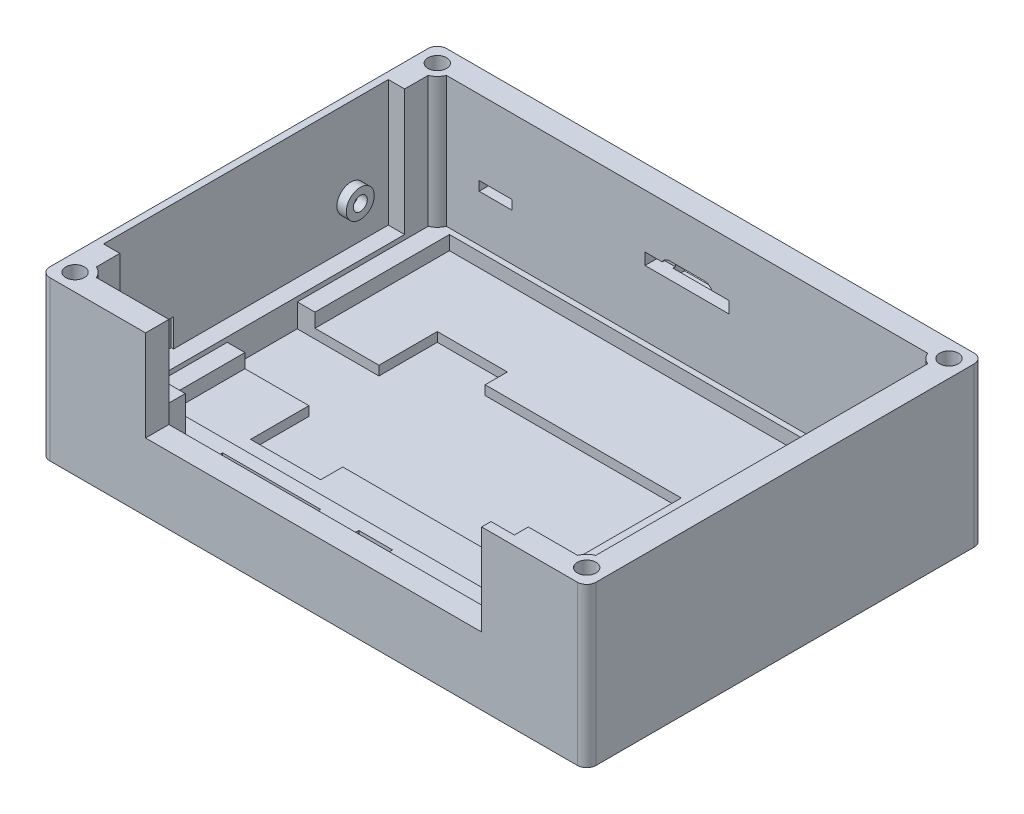
from build123d import *

# Parameters (mm, degrees)
SKETCH1_W                = 117
SKETCH1_H                = 85
BOSS_EXTRUDE1_DEPTH      = 34
SKETCH2_W                = 107
SKETCH2_H                = 75
CUT_EXTRUDE1_DEPTH       = 28
CUT_EXTRUDE2_DEPTH       = 28
CUT_EXTRUDE2_DEPTH_BACK  = 28
SKETCH3_R                = 2
SKETCH11_R               = 3.5
BOSS_EXTRUDE3_DEPTH      = 28
SKETCH13_R               = 2
CUT_EXTRUDE9_DEPTH       = 80.903066274
SKETCH14_W               = 102
SKETCH14_H               = 62
CUT_EXTRUDE10_DEPTH      = 3
SKETCH15_W               = 61
SKETCH15_H               = 40
CUT_EXTRUDE11_DEPTH      = 3.5
SKETCH16_W               = 15
SKETCH16_H               = 6
CUT_EXTRUDE12_DEPTH      = 0.5
CUT_EXTRUDE13_DEPTH      = 5
SKETCH20_W               = 72
SKETCH20_H               = 25
CUT_EXTRUDE14_DEPTH      = 5
SKETCH21_W               = 7
SKETCH21_H               = 2
CUT_EXTRUDE15_DEPTH      = 2
SKETCH22_W               = 7
SKETCH22_H               = 2
BOSS_EXTRUDE5_DEPTH      = 2.5
SKETCH23_W               = 3
SKETCH23_H               = 1.5
BOSS_EXTRUDE6_DEPTH      = 2.5
CUT_EXTRUDE17_DEPTH      = 92.5
SKETCH38_W               = 21
SKETCH38_H               = 7
CUT_EXTRUDE22_DEPTH      = 4
CUT_EXTRUDE23_DEPTH      = 80.072751312
CUT_EXTRUDE23_DEPTH_BACK = 80.072751312
SKETCH39_R               = 1.6
SKETCH39_W               = 8
SKETCH39_H               = 4
SKETCH40_W               = 7.2
SKETCH40_H               = 7.2
CUT_EXTRUDE24_DEPTH      = 4
SKETCH41_R               = 2.5
CUT_EXTRUDE25_DEPTH      = 4
FILLET5_R                = 2
FILLET6_R                = 2
FILLET7_R                = 2
FILLET8_R                = 2
SKETCH6_W                = 42
SKETCH6_H                = 30.5
CUT_EXTRUDE26_DEPTH      = 5
CUT_EXTRUDE27_DEPTH      = 5
CUT_EXTRUDE27_DEPTH_BACK = 2
SKETCH43_R               = 3
SKETCH43_R_2             = 1.5
BOSS_EXTRUDE7_DEPTH      = 2
SKETCH44_W               = 5
SKETCH44_H               = 15.5
CUT_EXTRUDE28_DEPTH      = 3
SKETCH45_W               = 18
SKETCH45_H               = 2.5
CUT_EXTRUDE29_DEPTH      = 3
SKETCH47_W               = 11.05
SKETCH47_H               = 7
CUT_EXTRUDE30_DEPTH      = 2.5
SKETCH48_W               = 7
SKETCH48_H               = 6
BOSS_EXTRUDE8_DEPTH      = 10
SKETCH49_W               = 7
SKETCH49_H               = 6
BOSS_EXTRUDE9_DEPTH      = 10
SKETCH51_R               = 1.5
CUT_EXTRUDE31_DEPTH      = 8
SKETCH50_R               = 1.5
CUT_EXTRUDE32_DEPTH      = 8


with BuildPart() as part:
    # Sketch1 → Boss-Extrude1 (new body)
    with BuildSketch(Plane(origin=(0, 0, 0), x_dir=(1, 0, 0), z_dir=(0, 1, 0))):
        Rectangle(SKETCH1_W, SKETCH1_H)
    extrude(amount=BOSS_EXTRUDE1_DEPTH)

    # Sketch2 → Cut-Extrude1 (cut)
    with BuildSketch(Plane(origin=(0, 34, 0), x_dir=(1, 0, 0), z_dir=(0, 1, 0))):
        Rectangle(SKETCH2_W, SKETCH2_H)
    extrude(amount=-CUT_EXTRUDE1_DEPTH, mode=Mode.SUBTRACT)

    # Sketch3 → Cut-Extrude2 (cut, two sides: drawn at the far end of the back side and taken through both)
    with BuildSketch(Plane(origin=(0, 6, 0), x_dir=(1, 0, 0), z_dir=(0, 1, 0)).offset(-CUT_EXTRUDE2_DEPTH_BACK)):
        with Locations((54.8, -38.8)):
            Circle(SKETCH3_R)
        with Locations((54.8, 38.8)):
            Circle(SKETCH3_R)
        with Locations((-54.8, 38.8)):
            Circle(SKETCH3_R)
        with Locations((-54.8, -38.8)):
            Circle(SKETCH3_R)
    extrude(amount=CUT_EXTRUDE2_DEPTH + CUT_EXTRUDE2_DEPTH_BACK, mode=Mode.SUBTRACT)

    # Sketch11 → Boss-Extrude3 (add)
    with BuildSketch(Plane(origin=(0, 6, 0), x_dir=(1, 0, 0), z_dir=(0, 1, 0))):
        with Locations((-54.8, -38.8)):
            Circle(SKETCH11_R)
        with Locations((-54.8, 38.8)):
            Circle(SKETCH11_R)
        with Locations((54.8, -38.8)):
            Circle(SKETCH11_R)
        with Locations((54.8, 38.8)):
            Circle(SKETCH11_R)
    extrude(amount=BOSS_EXTRUDE3_DEPTH)

    # Sketch13 → Cut-Extrude9 (cut, through all)
    with BuildSketch(Plane(origin=(0, 34, 0), x_dir=(1, 0, 0), z_dir=(0, 1, 0))):
        with Locations((-54.8, 38.8)):
            Circle(SKETCH13_R)
        with Locations((54.8, 38.8)):
            Circle(SKETCH13_R)
        with Locations((-54.8, -38.8)):
            Circle(SKETCH13_R)
        with Locations((54.8, -38.8)):
            Circle(SKETCH13_R)
    extrude(amount=-CUT_EXTRUDE9_DEPTH, mode=Mode.SUBTRACT)

    # Sketch14 → Cut-Extrude10 (cut)
    with BuildSketch(Plane(origin=(0, 6, 0), x_dir=(1, 0, 0), z_dir=(0, 1, 0))):
        with Locations((1.3, 5.3)):
            Rectangle(SKETCH14_W, SKETCH14_H)
    extrude(amount=-CUT_EXTRUDE10_DEPTH, mode=Mode.SUBTRACT)

    # Sketch15 → Cut-Extrude11 (cut)
    with BuildSketch(Plane(origin=(-53.5, 0, 0), x_dir=(0, 0, -1), z_dir=(1, 0, 0))):
        with Locations((-0.000384638, 27)):
            Rectangle(SKETCH15_W, SKETCH15_H)
    extrude(amount=-CUT_EXTRUDE11_DEPTH, mode=Mode.SUBTRACT)

    # Sketch16 → Cut-Extrude12 (cut)
    with BuildSketch(Plane(origin=(-57, 0, 0), x_dir=(0, 0, -1), z_dir=(1, 0, 0))):
        with Locations((-23.000384638, 10)):
            Rectangle(SKETCH16_W, SKETCH16_H)
    extrude(amount=-CUT_EXTRUDE12_DEPTH, mode=Mode.SUBTRACT)

    # Sketch18 → Cut-Extrude13 (cut)
    with BuildSketch(Plane(origin=(0, 0, -42.5), x_dir=(-1, 0, 0), z_dir=(0, 0, -1))):
        with BuildLine():
            Line((-3.725, 23.5), (3.725, 23.5))
            ThreePointArc((3.725, 23.5), (5.475, 21.75), (3.725, 20))
            Line((3.725, 20), (-3.725, 20))
            ThreePointArc((-3.725, 20), (-5.475, 21.75), (-3.725, 23.5))
        make_face()
    extrude(amount=-CUT_EXTRUDE13_DEPTH, mode=Mode.SUBTRACT)

    # Sketch20 → Cut-Extrude14 (cut)
    with BuildSketch(Plane.XY.offset(42.5)):
        with Locations((0, 27)):
            Rectangle(SKETCH20_W, SKETCH20_H)
    extrude(amount=-CUT_EXTRUDE14_DEPTH, mode=Mode.SUBTRACT)

    # Sketch21 → Cut-Extrude15 (cut)
    with BuildSketch(Plane.XY.offset(-37.5)):
        with Locations((-41.050384638, 17)):
            Rectangle(SKETCH21_W, SKETCH21_H)
        with Locations((41.050384638, 17)):
            Rectangle(SKETCH21_W, SKETCH21_H)
    extrude(amount=-CUT_EXTRUDE15_DEPTH, mode=Mode.SUBTRACT)

    # Sketch22 → Boss-Extrude5 (add)
    with BuildSketch(Plane(origin=(0, 0, 37.5), x_dir=(-1, 0, 0), z_dir=(0, 0, -1))):
        with Locations((-43.800384638, 15)):
            Rectangle(SKETCH22_W, SKETCH22_H)
        with Locations((41.990384638, 15)):
            Rectangle(SKETCH22_W, SKETCH22_H)
    extrude(amount=BOSS_EXTRUDE5_DEPTH)

    # Sketch23 → Boss-Extrude6 (add)
    with BuildSketch(Plane(origin=(0, 0, 37.5), x_dir=(-1, 0, 0), z_dir=(0, 0, -1))):
        with Locations((-43.800384638, 13.25)):
            Rectangle(SKETCH23_W, SKETCH23_H)
        with Locations((43.800384638, 13.25)):
            Rectangle(SKETCH23_W, SKETCH23_H)
    extrude(amount=BOSS_EXTRUDE6_DEPTH)

    # Sketch25 → Cut-Extrude17 (cut)
    with BuildSketch(Plane(origin=(45.300384638, 0, 0), x_dir=(0, 0, -1), z_dir=(1, 0, 0))):
        Polygon((-35, 14), (-37.5, 12.5), (-35, 12.5), align=None)
    extrude(amount=-CUT_EXTRUDE17_DEPTH, mode=Mode.SUBTRACT)

    # Sketch38 → Cut-Extrude22 (cut)
    with BuildSketch(Plane(origin=(0, 6, 0), x_dir=(1, 0, 0), z_dir=(0, 1, 0))):
        with Locations((-23, -32)):
            Rectangle(SKETCH38_W, SKETCH38_H)
    extrude(amount=-CUT_EXTRUDE22_DEPTH, mode=Mode.SUBTRACT)

    # Sketch39 → Cut-Extrude23 (cut, two sides: drawn at the far end of the back side and taken through both)
    with BuildSketch(Plane(origin=(0, 2, 0), x_dir=(1, 0, 0), z_dir=(0, 1, 0)).offset(-CUT_EXTRUDE23_DEPTH_BACK)):
        with Locations((-31, -32)):
            Circle(SKETCH39_R)
        with Locations((-15, -32)):
            Circle(SKETCH39_R)
        with Locations((-23, -32)):
            Rectangle(SKETCH39_W, SKETCH39_H)
    extrude(amount=CUT_EXTRUDE23_DEPTH + CUT_EXTRUDE23_DEPTH_BACK, mode=Mode.SUBTRACT)

    # Sketch40 → Cut-Extrude24 (cut)
    with BuildSketch(Plane(origin=(0, 6, 0), x_dir=(1, 0, 0), z_dir=(0, 1, 0))):
        with Locations((-0.9, -31.9)):
            Rectangle(SKETCH40_W, SKETCH40_H)
    extrude(amount=-CUT_EXTRUDE24_DEPTH, mode=Mode.SUBTRACT)

    # Sketch41 → Cut-Extrude25 (cut)
    with BuildSketch(Plane(origin=(0, 2, 0), x_dir=(1, 0, 0), z_dir=(0, 1, 0))):
        with Locations((-0.9, -31.9)):
            Circle(SKETCH41_R)
    extrude(amount=-CUT_EXTRUDE25_DEPTH, mode=Mode.SUBTRACT)

    # Fillet5
    fillet5_edges = [part.edges().sort_by_distance(p)[0] for p in [
        (-58.5, 17, 42.5),
    ]]
    fillet(fillet5_edges, radius=FILLET5_R)

    # Fillet6
    fillet6_edges = [part.edges().sort_by_distance(p)[0] for p in [
        (58.5, 17, 42.5),
    ]]
    fillet(fillet6_edges, radius=FILLET6_R)

    # Fillet7
    fillet7_edges = [part.edges().sort_by_distance(p)[0] for p in [
        (58.5, 17, -42.5),
    ]]
    fillet(fillet7_edges, radius=FILLET7_R)

    # Fillet8
    fillet8_edges = [part.edges().sort_by_distance(p)[0] for p in [
        (-58.5, 17, -42.5),
    ]]
    fillet(fillet8_edges, radius=FILLET8_R)

    # Sketch6 → Cut-Extrude26 (cut)
    with BuildSketch(Plane(origin=(22.627458043, 6, 6.502354234), x_dir=(1, 0, 0), z_dir=(0, 1, 0))):
        with Locations((-22.627458043, 6.502354234)):
            Rectangle(SKETCH6_W, SKETCH6_H)
    extrude(amount=-CUT_EXTRUDE26_DEPTH, mode=Mode.SUBTRACT)

    # Sketch42 → Cut-Extrude27 (cut, two sides: drawn at the far end of the back side and taken through both)
    with BuildSketch(Plane(origin=(0, 3, 0), x_dir=(1, 0, 0), z_dir=(0, 1, 0)).offset(-CUT_EXTRUDE27_DEPTH_BACK)):
        Polygon((-21, -20), (-36, -20), (-36, -7.5), (-53.5, -7.5), (-53.5, 7.5), (-36, 7.5), (-36, 20), (-21, 20), align=None)
    extrude(amount=CUT_EXTRUDE27_DEPTH + CUT_EXTRUDE27_DEPTH_BACK, mode=Mode.SUBTRACT)

    # Sketch43 → Boss-Extrude7 (add)
    with BuildSketch(Plane(origin=(-57, 0, 0), x_dir=(0, 0, -1), z_dir=(1, 0, 0))):
        with Locations((22.499615362, 16)):
            Circle(SKETCH43_R)
        with Locations((22.499615362, 16)):
            Circle(SKETCH43_R_2, mode=Mode.SUBTRACT)
    extrude(amount=BOSS_EXTRUDE7_DEPTH)

    # Sketch44 → Cut-Extrude28 (cut)
    with BuildSketch(Plane(origin=(0, 0, 37.5), x_dir=(-1, 0, 0), z_dir=(0, 0, -1))):
        with Locations((-38.5, 26.25)):
            Rectangle(SKETCH44_W, SKETCH44_H)
    extrude(amount=-CUT_EXTRUDE28_DEPTH, mode=Mode.SUBTRACT)

    # Sketch45 → Cut-Extrude29 (cut)
    with BuildSketch(Plane.XY.offset(-37.5)):
        with Locations((0, 21.25)):
            Rectangle(SKETCH45_W, SKETCH45_H)
    extrude(amount=-CUT_EXTRUDE29_DEPTH, mode=Mode.SUBTRACT)

    # Sketch47 → Cut-Extrude30 (cut)
    with BuildSketch(Plane(origin=(0, 0, -42.5), x_dir=(-1, 0, 0), z_dir=(0, 0, -1))):
        with Locations((0, 21.75)):
            Rectangle(SKETCH47_W, SKETCH47_H)
    extrude(amount=-CUT_EXTRUDE30_DEPTH, mode=Mode.SUBTRACT)

    # Sketch48 → Boss-Extrude8 (add)
    with BuildSketch(Plane(origin=(0, 16, 0), x_dir=(1, 0, 0), z_dir=(0, 1, 0))):
        with Locations((43.800384638, -34.5)):
            Rectangle(SKETCH48_W, SKETCH48_H)
    extrude(amount=-BOSS_EXTRUDE8_DEPTH)

    # Sketch49 → Boss-Extrude9 (add)
    with BuildSketch(Plane(origin=(0, 16, 0), x_dir=(1, 0, 0), z_dir=(0, 1, 0))):
        with Locations((-41.990384638, -34.5)):
            Rectangle(SKETCH49_W, SKETCH49_H)
    extrude(amount=-BOSS_EXTRUDE9_DEPTH)

    # Sketch51 → Cut-Extrude31 (cut)
    with BuildSketch(Plane(origin=(0, 16, 0), x_dir=(1, 0, 0), z_dir=(0, 1, 0))):
        with Locations((-41.985384638, -34.5)):
            Circle(SKETCH51_R)
    extrude(amount=-CUT_EXTRUDE31_DEPTH, mode=Mode.SUBTRACT)

    # Sketch50 → Cut-Extrude32 (cut)
    with BuildSketch(Plane(origin=(0, 16, 0), x_dir=(1, 0, 0), z_dir=(0, 1, 0))):
        with Locations((43.795384638, -34.5)):
            Circle(SKETCH50_R)
    extrude(amount=-CUT_EXTRUDE32_DEPTH, mode=Mode.SUBTRACT)


solid = part.part
